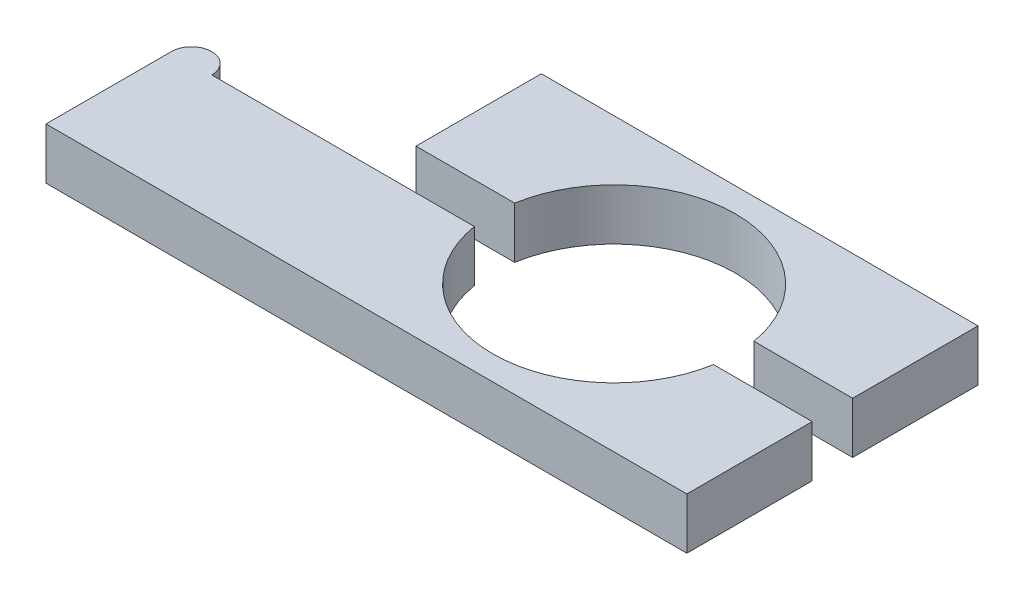
from build123d import *

# Parameters (mm, degrees)
SKETCH1_W           = 158.5
SKETCH1_H           = 72
BOSS_EXTRUDE1_DEPTH = 12.7
SKETCH2_R           = 30
CUT_EXTRUDE1_DEPTH  = 13.7
SKETCH3_W           = 158.5
SKETCH3_H           = 10
CUT_EXTRUDE3_DEPTH  = 13.7
SKETCH4_W           = 50.5
SKETCH4_H           = 31
CUT_EXTRUDE4_DEPTH  = 13.7
BOSS_EXTRUDE2_DEPTH = 12.7


with BuildPart() as part:
    # Sketch1 → Boss-Extrude1 (new body)
    with BuildSketch(Plane(origin=(0, 43.113273326, 0), x_dir=(1, 0, 0), z_dir=(0, 1, 0))):
        with Locations((-57.805385746, 31.84742784)):
            Rectangle(SKETCH1_W, SKETCH1_H)
    extrude(amount=-BOSS_EXTRUDE1_DEPTH)

    # Sketch2 → Cut-Extrude1 (cut, through all)
    with BuildSketch(Plane(origin=(0, 43.113273326, 0), x_dir=(1, 0, 0), z_dir=(0, 1, 0))):
        with Locations((-32.555385746, 31.84742784)):
            Circle(SKETCH2_R)
    extrude(amount=-CUT_EXTRUDE1_DEPTH, mode=Mode.SUBTRACT)

    # Sketch3 → Cut-Extrude3 (cut, through all)
    with BuildSketch(Plane(origin=(0, 43.113273326, 0), x_dir=(1, 0, 0), z_dir=(0, 1, 0))):
        with Locations((-57.805385746, 31.84742784)):
            Rectangle(SKETCH3_W, SKETCH3_H)
    extrude(amount=-CUT_EXTRUDE3_DEPTH, mode=Mode.SUBTRACT)

    # Sketch4 → Cut-Extrude4 (cut, through all)
    with BuildSketch(Plane.XZ.offset(-30.413273326)):
        with Locations((-111.805385746, -52.34742784)):
            Rectangle(SKETCH4_W, SKETCH4_H)
    extrude(amount=-CUT_EXTRUDE4_DEPTH, mode=Mode.SUBTRACT)

    # Sketch5 → Boss-Extrude2 (add)
    with BuildSketch(Plane.XZ.offset(-30.413273326)):
        with BuildLine():
            Line((-137.055385746, -26.84742784), (-127.055385746, -26.84742784))
            ThreePointArc((-127.055385746, -26.84742784), (-132.055385746, -31.84742784), (-137.055385746, -26.84742784))
        make_face()
    extrude(amount=-BOSS_EXTRUDE2_DEPTH)


solid = part.part
